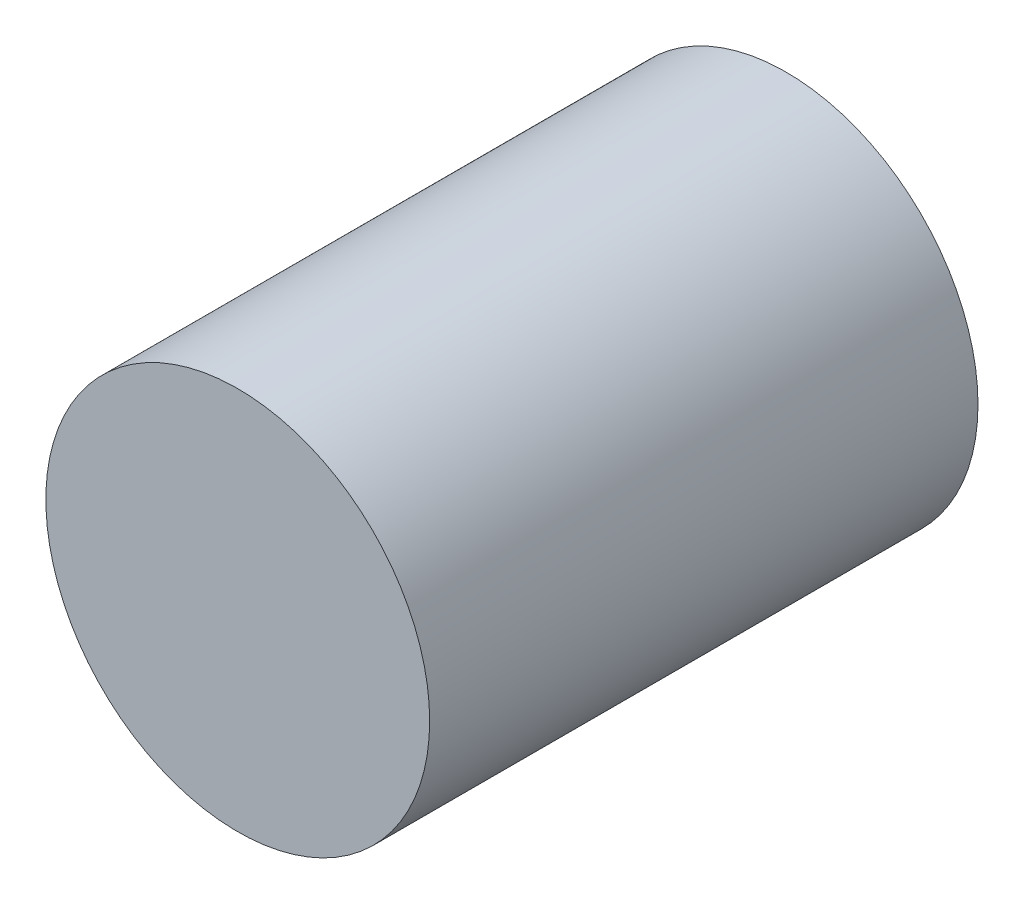
from build123d import *

# Parameters (mm, degrees)
SKETCH_1_R      = 140
EXTRUDE_1_DEPTH = 400


with BuildPart() as part:
    # 草图1 → 凸台-拉伸1 (new body)
    with BuildSketch(Plane.XY):
        Circle(SKETCH_1_R)
    extrude(amount=EXTRUDE_1_DEPTH)


solid = part.part
